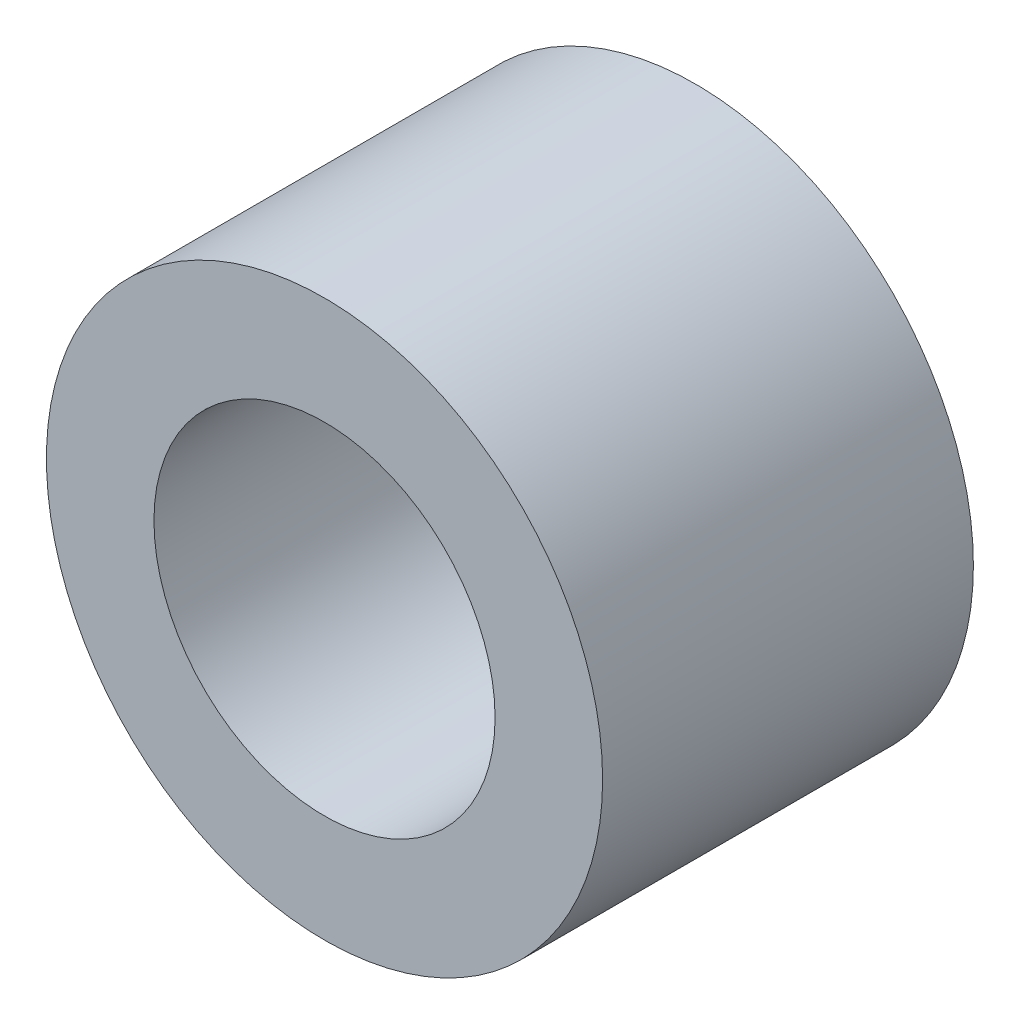
from build123d import *

# Parameters (mm, degrees)
SKETCH1_R      = 2.38125
SKETCH1_R_2    = 1.4605
EXTRUDE1_DEPTH = 1.5875


with BuildPart() as part:
    # Sketch1 → Extrude1 (new body, symmetric)
    with BuildSketch(Plane.XY):
        Circle(SKETCH1_R)
        Circle(SKETCH1_R_2, mode=Mode.SUBTRACT)
    extrude(amount=EXTRUDE1_DEPTH, both=True)


solid = part.part
